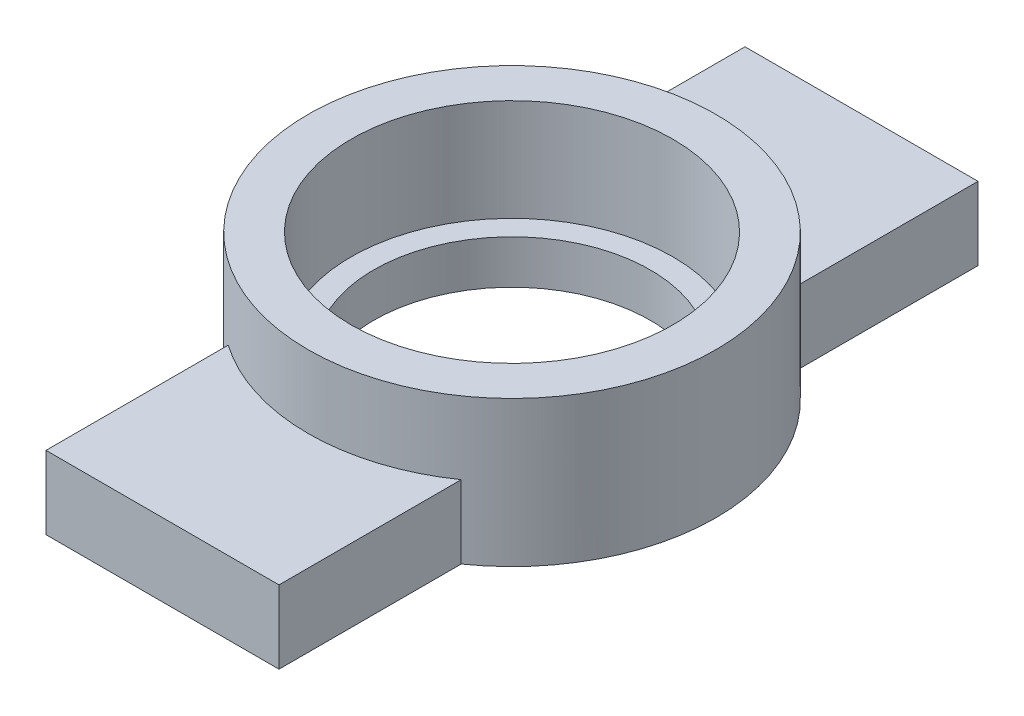
from build123d import *

# Parameters (mm, degrees)
SKETCH1_R           = 14
SKETCH1_R_2         = 11.05
BOSS_EXTRUDE1_DEPTH = 10
SKETCH1_3_R         = 11.05
SKETCH1_3_R_2       = 9.5
BOSS_EXTRUDE2_DEPTH = 3
BOSS_EXTRUDE3_START = -2.510875
SKETCH4_W           = 16
SKETCH4_H           = 5.016393312
BOSS_EXTRUDE3_DEPTH = 12.510875


with BuildPart() as part:
    # Sketch1 → Boss-Extrude1 (new body)
    with BuildSketch(Plane(origin=(0, 0, 0), x_dir=(1, 0, 0), z_dir=(0, 1, 0))):
        Circle(SKETCH1_R)
        Circle(SKETCH1_R_2, mode=Mode.SUBTRACT)
    extrude(amount=BOSS_EXTRUDE1_DEPTH)

    # Sketch1_3 → Boss-Extrude2 (add)
    with BuildSketch(Plane(origin=(0, 0, 0), x_dir=(1, 0, 0), z_dir=(0, 1, 0))):
        Circle(SKETCH1_3_R)
        Circle(SKETCH1_3_R_2, mode=Mode.SUBTRACT)
    extrude(amount=BOSS_EXTRUDE2_DEPTH)

    # Sketch4 → Boss-Extrude3 (add)
    with BuildSketch(Plane.XY.offset(14).offset(BOSS_EXTRUDE3_START)):
        with Locations((0, 2.508196656)):
            Rectangle(SKETCH4_W, SKETCH4_H)
    boss_extrude3 = extrude(amount=BOSS_EXTRUDE3_DEPTH)

    # Mirror1: Boss-Extrude3 across plane
    add(boss_extrude3.mirror(Plane.XY))


solid = part.part
